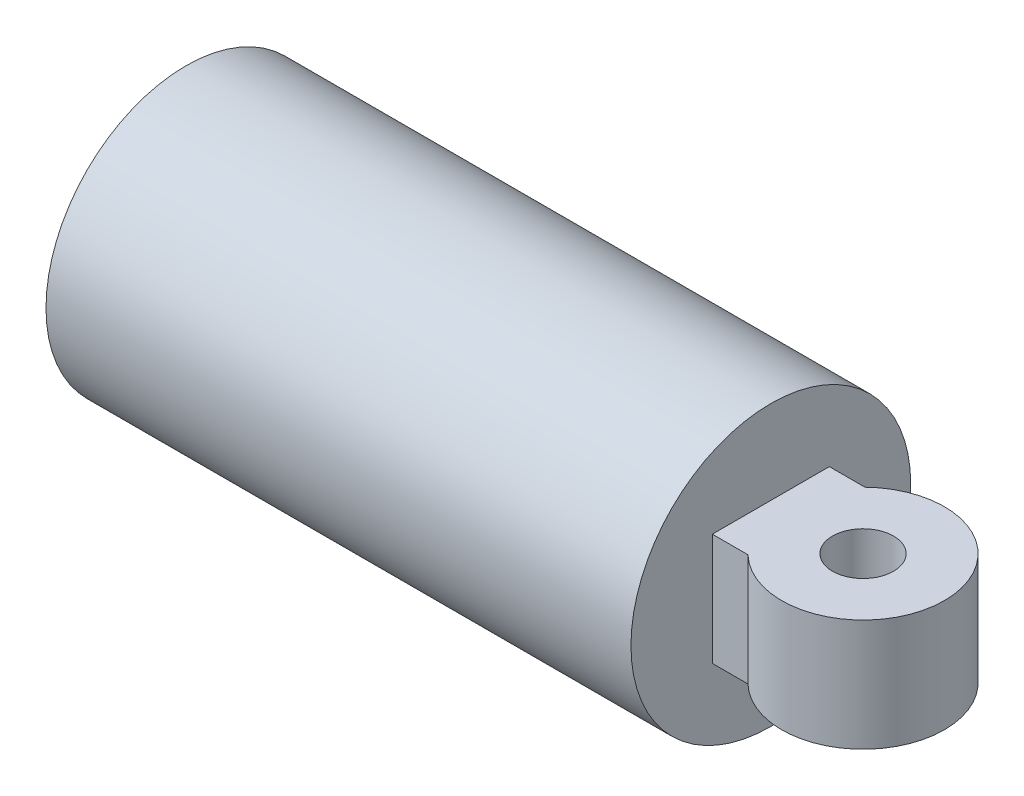
from build123d import *

# Parameters (mm, degrees)
SKETCH2_R           = 6
BOSS_EXTRUDE1_DEPTH = 11


with BuildPart() as part:
    # Sketch1 → Revolve1 (revolve)
    with BuildSketch(Plane(origin=(0, 0, 0), x_dir=(1, 0, 0), z_dir=(0, 1, 0))):
        Polygon((0, 0), (-13, 0), (-13, 12.5), (-113, 12.5), (-113, 14.5), (-13, 14.5), (-13, 26.5), (-115, 26.5), (-115, 27.5), (0, 27.5), align=None)
    revolve(axis=Axis((0, 0, 0), (-1, 0, 0)))

    # Sketch2 → Boss-Extrude1 (add, symmetric)
    with BuildSketch(Plane(origin=(0, 0, 0), x_dir=(1, 0, 0), z_dir=(0, 1, 0))):
        with BuildLine():
            Line((0, 11.5), (7, 11.5))
            ThreePointArc((7, 11.5), (34.124297731, 0), (7, -11.5))
            Line((7, -11.5), (0, -11.5))
            Line((0, -11.5), (0, 11.5))
        make_face()
        with Locations((18.124297731, 0)):
            Circle(SKETCH2_R, mode=Mode.SUBTRACT)
    extrude(amount=BOSS_EXTRUDE1_DEPTH, both=True)


solid = part.part
